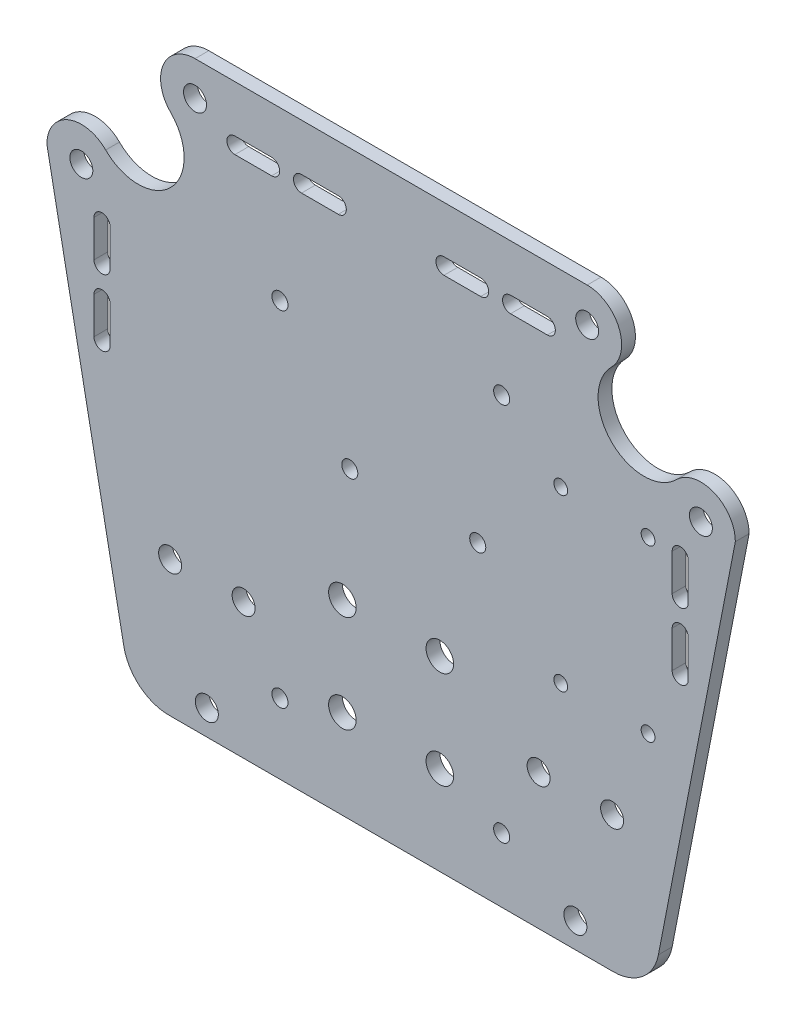
from build123d import *

# Parameters (mm, degrees)
ESQUISSE1_W             = 53.21
ESQUISSE1_H             = 101.6
ESQUISSE1_R             = 1.75
BOSS_EXTRU_1_DEPTH      = 3
ESQUISSE2_R             = 2.5
BOSS_EXTRU_2_DEPTH      = 3
ESQUISSE3_R             = 1.5
ENL_V_MAT_EXTRU_1_DEPTH = 3
ESQUISSE4_R             = 3
ENL_V_MAT_EXTRU_2_DEPTH = 4


with BuildPart() as part:
    # Esquisse1 → Boss.-Extru.1 (new body)
    with BuildSketch(Plane.XY):
        Rectangle(ESQUISSE1_W, ESQUISSE1_H)
        with Locations((-24.195, -35.5)):
            Circle(ESQUISSE1_R, mode=Mode.SUBTRACT)
        with Locations((24.065, -36.8)):
            Circle(ESQUISSE1_R, mode=Mode.SUBTRACT)
        with Locations((-8.995, 15.3)):
            Circle(ESQUISSE1_R, mode=Mode.SUBTRACT)
        with Locations((18.855, 15.3)):
            Circle(ESQUISSE1_R, mode=Mode.SUBTRACT)
        with Locations((-24.195, 39.43)):
            Circle(ESQUISSE1_R, mode=Mode.SUBTRACT)
        with Locations((24.065, 45.75)):
            Circle(ESQUISSE1_R, mode=Mode.SUBTRACT)
    extrude(amount=BOSS_EXTRU_1_DEPTH)

    # Esquisse2 → Boss.-Extru.2 (add)
    with BuildSketch(Plane.XY.offset(3)):
        with BuildLine():
            Line((0, 50.8), (0, 75.8))
            Line((0, 75.8), (-42.675883861, 75.8))
            ThreePointArc((-42.675883861, 75.8), (-49.604980355, 71.170125743), (-47.97918472, 62.996699141))
            ThreePointArc((-47.97918472, 62.996699141), (-47.97918472, 48.854563517), (-62.121320344, 48.854563517))
            ThreePointArc((-62.121320344, 48.854563517), (-70.294746945, 50.480359152), (-74.924621202, 43.551262658))
            Line((-74.924621202, 43.551262658), (-58.176555089, -42.706044052))
            ThreePointArc((-58.176555089, -42.706044052), (-54.721472053, -48.51558295), (-48.359885793, -50.8))
            Line((-48.359885793, -50.8), (-26.605, -50.8))
            Line((-26.605, -50.8), (-26.605, 50.8))
            Line((-26.605, 50.8), (0, 50.8))
        make_face()
        with Locations((-40.105, -45.3)):
            Circle(ESQUISSE2_R, mode=Mode.SUBTRACT)
        with Locations((-32.105, -21.3)):
            Circle(ESQUISSE2_R, mode=Mode.SUBTRACT)
        with Locations((-48.105, -21.3)):
            Circle(ESQUISSE2_R, mode=Mode.SUBTRACT)
        with Locations((-67.424621202, 43.551262658)):
            Circle(ESQUISSE2_R, mode=Mode.SUBTRACT)
        with Locations((-42.675883861, 68.3)):
            Circle(ESQUISSE2_R, mode=Mode.SUBTRACT)
        with BuildLine():
            Line((-61.174621202, 34.875473497), (-61.174621202, 26.875473497))
            ThreePointArc((-61.174621202, 26.875473497), (-62.924621202, 25.125473497), (-64.674621202, 26.875473497))
            Line((-64.674621202, 26.875473497), (-64.674621202, 34.875473497))
            ThreePointArc((-64.674621202, 34.875473497), (-62.924621202, 36.625473497), (-61.174621202, 34.875473497))
        make_face(mode=Mode.SUBTRACT)
        with BuildLine():
            Line((-61.174621202, 20.375473497), (-61.174621202, 12.375473497))
            ThreePointArc((-61.174621202, 12.375473497), (-62.924621202, 10.625473497), (-64.674621202, 12.375473497))
            Line((-64.674621202, 12.375473497), (-64.674621202, 20.375473497))
            ThreePointArc((-64.674621202, 20.375473497), (-62.924621202, 22.125473497), (-61.174621202, 20.375473497))
        make_face(mode=Mode.SUBTRACT)
        with BuildLine():
            Line((-34.0000947, 62.05), (-26.0000947, 62.05))
            ThreePointArc((-26.0000947, 62.05), (-24.2500947, 63.8), (-26.0000947, 65.55))
            Line((-26.0000947, 65.55), (-34.0000947, 65.55))
            ThreePointArc((-34.0000947, 65.55), (-35.7500947, 63.8), (-34.0000947, 62.05))
        make_face(mode=Mode.SUBTRACT)
        with BuildLine():
            Line((-19.5000947, 62.05), (-11.5000947, 62.05))
            ThreePointArc((-11.5000947, 62.05), (-9.7500947, 63.8), (-11.5000947, 65.55))
            Line((-11.5000947, 65.55), (-19.5000947, 65.55))
            ThreePointArc((-19.5000947, 65.55), (-21.2500947, 63.8), (-19.5000947, 62.05))
        make_face(mode=Mode.SUBTRACT)
    boss_extru_2 = extrude(amount=-BOSS_EXTRU_2_DEPTH)

    # Symétrie1: Boss.-Extru.2 across plane
    add(boss_extru_2.mirror(Plane(origin=(0, 50.8, 0), x_dir=(0, 0, 1), z_dir=(1, 0, 0))))

    # Esquisse3 → Enlèv. mat.-Extru.1 (cut)
    with BuildSketch(Plane.XY.offset(3)):
        with Locations((36.924621202, 34.875473497)):
            Circle(ESQUISSE3_R)
        with Locations((55.924621202, 34.875473497)):
            Circle(ESQUISSE3_R)
        with Locations((36.924621202, -2.124526503)):
            Circle(ESQUISSE3_R)
        with Locations((55.924621202, -2.124526503)):
            Circle(ESQUISSE3_R)
    extrude(amount=-ENL_V_MAT_EXTRU_1_DEPTH, mode=Mode.SUBTRACT)

    # Esquisse4 → Enlèv. mat.-Extru.2 (cut, through all)
    with BuildSketch(Plane.XY.offset(3)):
        with Locations((-10.606601718, -10.193398282)):
            Circle(ESQUISSE4_R)
        with Locations((10.606601718, -10.193398282)):
            Circle(ESQUISSE4_R)
        with Locations((-10.606601718, -31.406601718)):
            Circle(ESQUISSE4_R)
        with Locations((10.606601718, -31.406601718)):
            Circle(ESQUISSE4_R)
    extrude(amount=-ENL_V_MAT_EXTRU_2_DEPTH, mode=Mode.SUBTRACT)


solid = part.part
